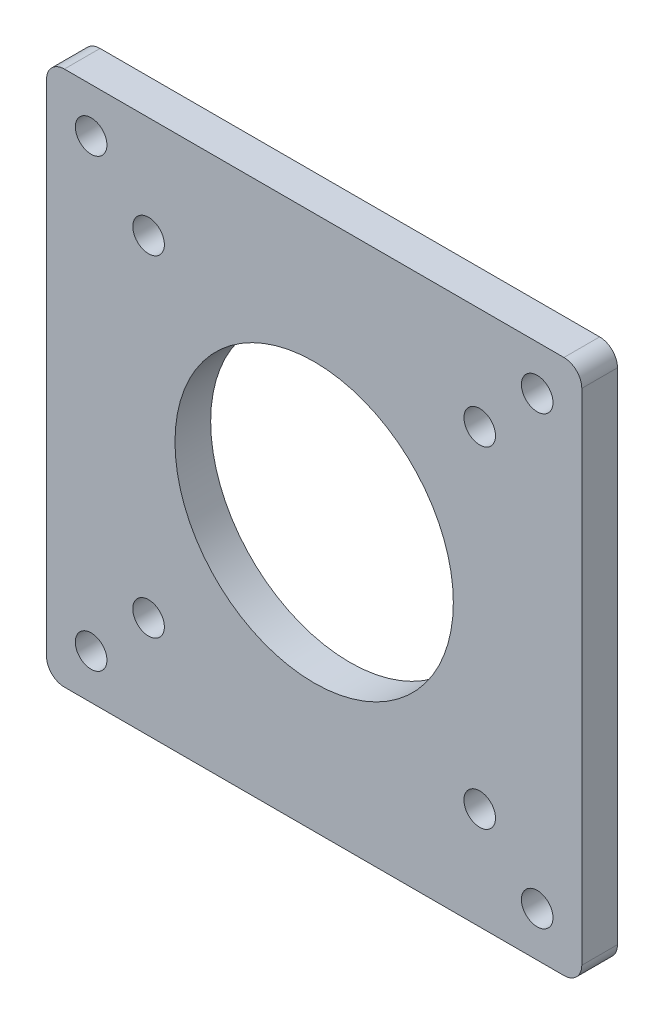
from build123d import *

# Parameters (mm, degrees)
SKETCH1_W             = 61.48
SKETCH1_H             = 61.48
SKETCH1_R             = 2.2479
SKETCH1_R_2           = 19.812
BOSS_EXTRUDE1_DEPTH   = 5.08
FILLET1_R             = 2.54
BOSS_EXTRUDE2_DEPTH   = 5.08
SKETCH8_W             = 76.2
SKETCH8_H             = 76.2
SKETCH8_W_2           = 61.48
SKETCH8_H_2           = 61.48
BOSS_EXTRUDE3_DEPTH   = 5.08
F_8_CLEARANCE_HOLE1_D = 4.4958
FILLET2_R             = 2.54


with BuildPart() as part:
    # Sketch1 → Boss-Extrude1 (new body)
    with BuildSketch(Plane.XY):
        Rectangle(SKETCH1_W, SKETCH1_H)
        with Locations((-23.57, 23.57)):
            Circle(SKETCH1_R, mode=Mode.SUBTRACT)
        with Locations((-23.57, -23.57)):
            Circle(SKETCH1_R, mode=Mode.SUBTRACT)
        with Locations((23.57, -23.57)):
            Circle(SKETCH1_R, mode=Mode.SUBTRACT)
        Circle(SKETCH1_R_2, mode=Mode.SUBTRACT)
        with Locations((23.57, 23.57)):
            Circle(SKETCH1_R, mode=Mode.SUBTRACT)
    extrude(amount=BOSS_EXTRUDE1_DEPTH)

    # Fillet1
    fillet1_edges = [part.edges().sort_by_distance(p)[0] for p in [
        (-30.74, 30.74, 2.54),
        (30.74, 30.74, 2.54),
        (30.74, -30.74, 2.54),
        (-30.74, -30.74, 2.54),
    ]]
    fillet(fillet1_edges, radius=FILLET1_R)

    # Sketch7 → Boss-Extrude2 (add, through all)
    with BuildSketch(Plane(origin=(0, 0, 0), x_dir=(-1, 0, 0), z_dir=(0, 0, -1))):
        with BuildLine():
            Line((-27.259871939, 36.240128061), (-21.759743879, 30.74))
            Line((-21.759743879, 30.74), (-30.74, 21.759743879))
            Line((-30.74, 21.759743879), (-36.240128061, 27.259871939))
            ThreePointArc((-36.240128061, 27.259871939), (-36.240128061, 36.240128061), (-27.259871939, 36.240128061))
        make_face()
        with BuildLine():
            Line((30.74, 21.759743879), (36.240128061, 27.259871939))
            ThreePointArc((36.240128061, 27.259871939), (36.240128061, 36.240128061), (27.259871939, 36.240128061))
            Line((27.259871939, 36.240128061), (21.759743879, 30.74))
            Line((21.759743879, 30.74), (30.74, 21.759743879))
        make_face()
        with BuildLine():
            Line((27.259871939, -36.240128061), (21.759743879, -30.74))
            Line((21.759743879, -30.74), (30.74, -21.759743879))
            Line((30.74, -21.759743879), (36.240128061, -27.259871939))
            ThreePointArc((36.240128061, -27.259871939), (36.240128061, -36.240128061), (27.259871939, -36.240128061))
        make_face()
        with BuildLine():
            Line((-30.74, -21.759743879), (-36.240128061, -27.259871939))
            ThreePointArc((-36.240128061, -27.259871939), (-36.240128061, -36.240128061), (-27.259871939, -36.240128061))
            Line((-27.259871939, -36.240128061), (-21.759743879, -30.74))
            Line((-21.759743879, -30.74), (-30.74, -21.759743879))
        make_face()
    extrude(amount=-BOSS_EXTRUDE2_DEPTH)

    # Sketch8 → Boss-Extrude3 (add, through all)
    with BuildSketch(Plane(origin=(0, 0, 0), x_dir=(-1, 0, 0), z_dir=(0, 0, -1))):
        Rectangle(SKETCH8_W, SKETCH8_H)
        Rectangle(SKETCH8_W_2, SKETCH8_H_2, mode=Mode.SUBTRACT)
    extrude(amount=-BOSS_EXTRUDE3_DEPTH)

    # #8 Clearance Hole1 (through all)
    with Locations(Plane(origin=(0, 0, 0), x_dir=(-1, 0, 0), z_dir=(0, 0, -1))):
        with Locations((31.75, 31.75), (0, 0), (31.75, -31.75), (-31.75, -31.75), (-31.75, 31.75)):
            Hole(F_8_CLEARANCE_HOLE1_D / 2)

    # Fillet2
    fillet2_edges = [part.edges().sort_by_distance(p)[0] for p in [
        (-38.1, 38.1, 2.54),
        (-38.1, -38.1, 2.54),
        (38.1, -38.1, 2.54),
        (38.1, 38.1, 2.54),
    ]]
    fillet(fillet2_edges, radius=FILLET2_R)


solid = part.part
